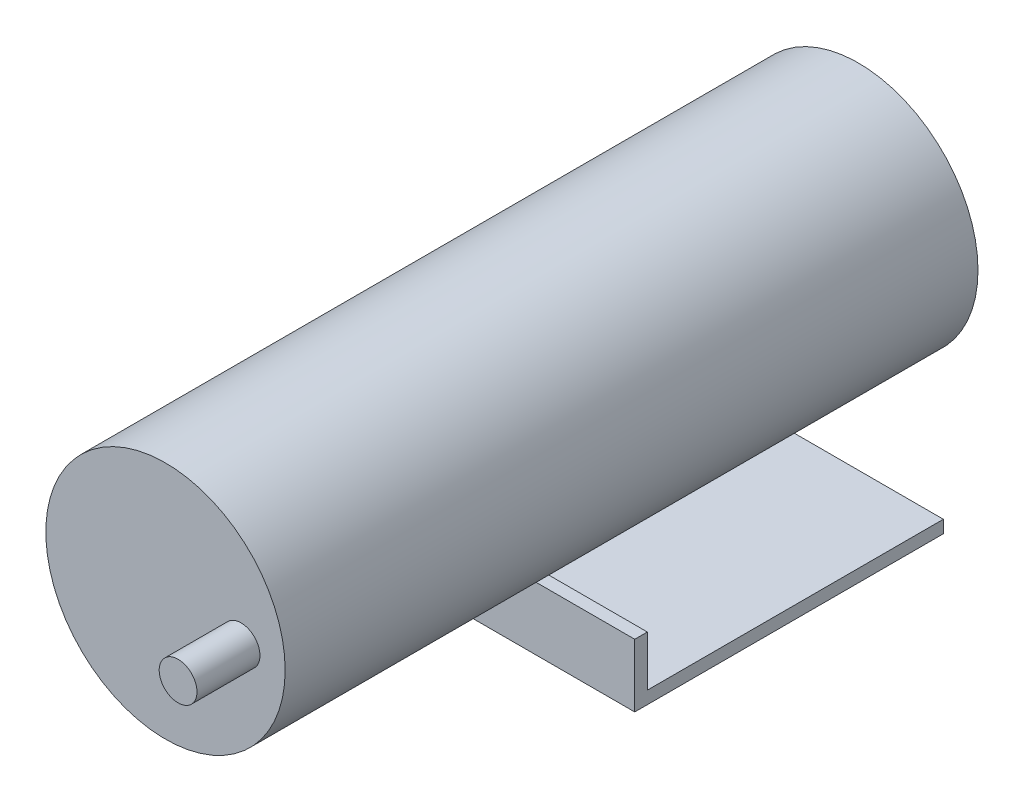
from build123d import *

# Parameters (mm, degrees)
ESQUISSE1_R             = 19
BOSS_EXTRU_1_DEPTH      = 110
ESQUISSE2_R             = 3
BOSS_EXTRU_2_DEPTH      = 10
BOSS_EXTRU_3_DEPTH      = 23.5
BOSS_EXTRU_3_DEPTH_BACK = 23.5


with BuildPart() as part:
    # Esquisse1 → Boss.-Extru.1 (new body)
    with BuildSketch(Plane.XY):
        Circle(ESQUISSE1_R)
    extrude(amount=BOSS_EXTRU_1_DEPTH)

    # Esquisse2 → Boss.-Extru.2 (add)
    with BuildSketch(Plane.XY.offset(110)):
        with Locations((12, 0)):
            Circle(ESQUISSE2_R)
    extrude(amount=BOSS_EXTRU_2_DEPTH)


with BuildPart() as body_2:
    # Esquisse3 → Boss.-Extru.3 (new, two sides: drawn at the far end of the back side and taken through both)
    with BuildSketch(Plane(origin=(0, 0, 0), x_dir=(0, 0, -1), z_dir=(1, 0, 0)).offset(-BOSS_EXTRU_3_DEPTH_BACK)):
        Polygon((-59, -19), (-59, -29), (-10, -29), (-10, -27), (-57, -27), (-57, -19), align=None)
    extrude(amount=BOSS_EXTRU_3_DEPTH + BOSS_EXTRU_3_DEPTH_BACK)


solid = Compound([part.part, body_2.part])
